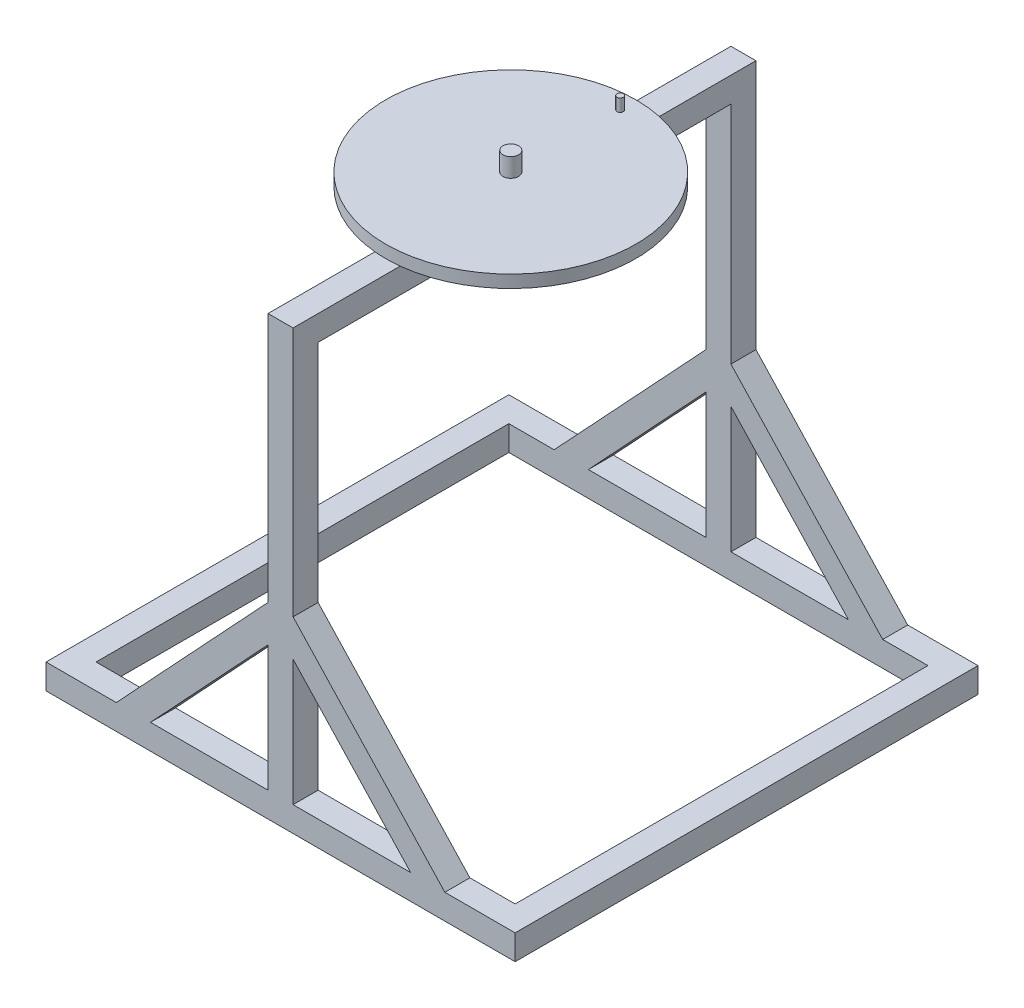
from build123d import *

# Parameters (mm, degrees)
BOSS_EXTRUDE1_DEPTH  = 740
SKETCH2_W            = 720
SKETCH2_H            = 660
CUT_EXTRUDE1_DEPTH   = 760
SKETCH4_W            = 25
SKETCH4_H            = 40
CUT_EXTRUDE2_DEPTH   = 817
SKETCH5_W            = 40
SKETCH5_H            = 40
BOSS_EXTRUDE2_DEPTH  = 740
SKETCH6_W            = 40
SKETCH6_H            = 40
BOSS_EXTRUDE3_DEPTH  = 740
SKETCH7_R            = 200
BOSS_EXTRUDE5_DEPTH  = 20
SKETCH8_R            = 12.5
BOSS_EXTRUDE6_DEPTH  = 30
SKETCH9_R            = 5
BOSS_EXTRUDE10_DEPTH = 20


with BuildPart() as part:
    # Sketch1 → Boss-Extrude1 (new body)
    with BuildSketch(Plane.XY):
        Polygon((-79.470198675, 173.509933775), (-79.470198675, -226.490066225), (-322.136865342, -486.490066225), (-459.470198675, -486.490066225), (-459.470198675, -526.490066225), (340.529801325, -526.490066225), (340.529801325, -486.490066225), (203.196467991, -486.490066225), (-39.470198675, -226.490066225), (-39.470198675, 173.509933775), align=None)
        Polygon((-79.470198675, -486.490066225), (-267.421439932, -486.490066225), (-79.470198675, -285.113736307), align=None, mode=Mode.SUBTRACT)
        Polygon((148.481042581, -486.490066225), (-39.470198675, -486.490066225), (-39.470198675, -285.113736307), align=None, mode=Mode.SUBTRACT)
    extrude(amount=BOSS_EXTRUDE1_DEPTH)

    # Sketch2 → Cut-Extrude1 (cut)
    with BuildSketch(Plane.XZ.offset(526.490066225)):
        with Locations((-59.470198675, 370)):
            Rectangle(SKETCH2_W, SKETCH2_H)
    extrude(amount=-CUT_EXTRUDE1_DEPTH, mode=Mode.SUBTRACT)

    # Sketch4 → Cut-Extrude2 (cut)
    with BuildSketch(Plane(origin=(0, 0, 0), x_dir=(-1, 0, 0), z_dir=(0, 0, -1))):
        with Locations((-328.029801325, -506.490066225)):
            Rectangle(SKETCH4_W, SKETCH4_H)
        with Locations((446.970198675, -506.490066225)):
            Rectangle(SKETCH4_W, SKETCH4_H)
    extrude(amount=-CUT_EXTRUDE2_DEPTH, mode=Mode.SUBTRACT)

    # Sketch5 → Boss-Extrude2 (add)
    with BuildSketch(Plane(origin=(0, 0, 0), x_dir=(-1, 0, 0), z_dir=(0, 0, -1))):
        with Locations((-295.529801325, -506.490066225)):
            Rectangle(SKETCH5_W, SKETCH5_H)
        with Locations((414.470198675, -506.490066225)):
            Rectangle(SKETCH5_W, SKETCH5_H)
    extrude(amount=-BOSS_EXTRUDE2_DEPTH)

    # Sketch6 → Boss-Extrude3 (add)
    with BuildSketch(Plane(origin=(0, 0, 0), x_dir=(-1, 0, 0), z_dir=(0, 0, -1))):
        with Locations((59.470198675, 153.509933775)):
            Rectangle(SKETCH6_W, SKETCH6_H)
    extrude(amount=-BOSS_EXTRUDE3_DEPTH)

    # Sketch7 → Boss-Extrude5 (add)
    with BuildSketch(Plane(origin=(0, 173.509933775, 0), x_dir=(1, 0, 0), z_dir=(0, 1, 0))):
        with Locations((-61.40332894, -370)):
            Circle(SKETCH7_R)
    extrude(amount=BOSS_EXTRUDE5_DEPTH)

    # Sketch8 → Boss-Extrude6 (add)
    with BuildSketch(Plane(origin=(0, 193.509933775, 0), x_dir=(1, 0, 0), z_dir=(0, 1, 0))):
        with Locations((-61.40332894, -370)):
            Circle(SKETCH8_R)
    extrude(amount=BOSS_EXTRUDE6_DEPTH)

    # Sketch9 → Boss-Extrude10 (add)
    with BuildSketch(Plane(origin=(0, 193.509933775, 0), x_dir=(1, 0, 0), z_dir=(0, 1, 0))):
        with Locations((-59.876755941, -196.697911229)):
            Circle(SKETCH9_R)
    extrude(amount=BOSS_EXTRUDE10_DEPTH)


solid = part.part
